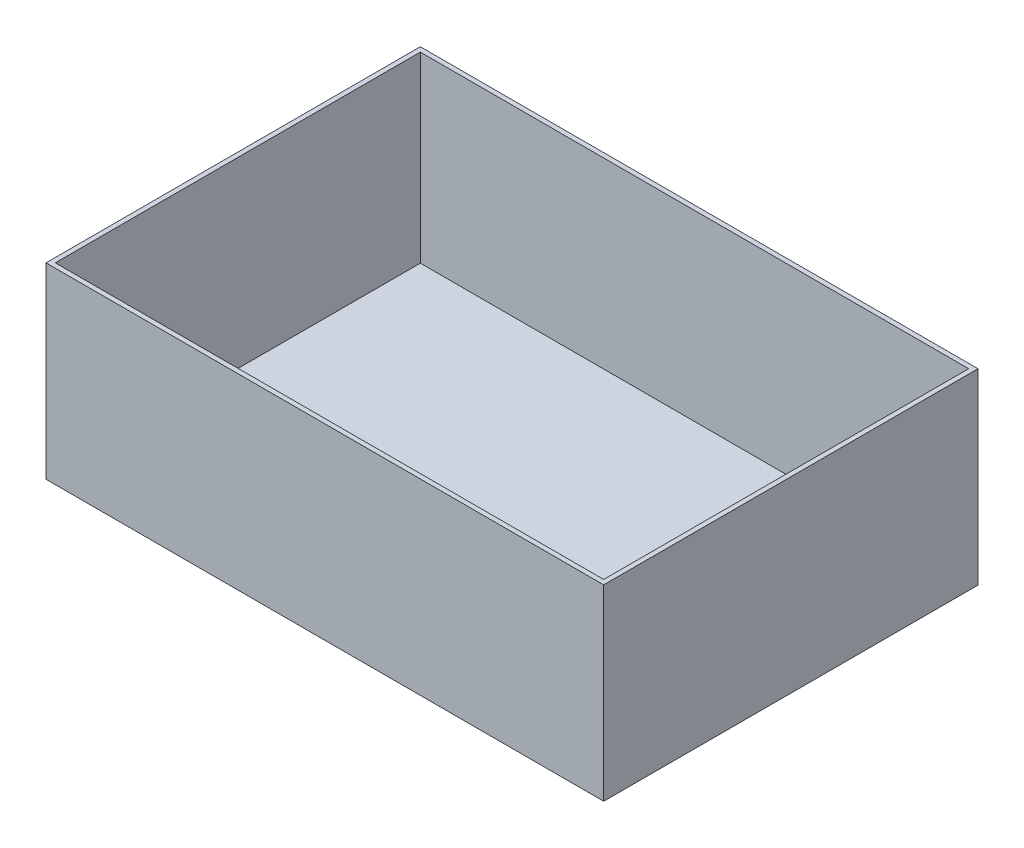
from build123d import *

# Parameters (mm, degrees)
SKETCH2_W           = 600
SKETCH2_H           = 399.38
BOSS_EXTRUDE1_DEPTH = 200
SHELL1_T            = 5.08


with BuildPart() as part:
    # Sketch2 → Boss-Extrude1 (new body)
    with BuildSketch(Plane(origin=(0, 0, 0), x_dir=(1, 0, 0), z_dir=(0, 1, 0))):
        with Locations((300, 199.69)):
            Rectangle(SKETCH2_W, SKETCH2_H)
    extrude(amount=BOSS_EXTRUDE1_DEPTH)

    # Shell1
    shell1_openings = [part.faces().sort_by_distance(p)[0] for p in [
        (300, 200, -199.69),
    ]]
    offset(amount=SHELL1_T, openings=shell1_openings, kind=Kind.INTERSECTION)


solid = part.part
